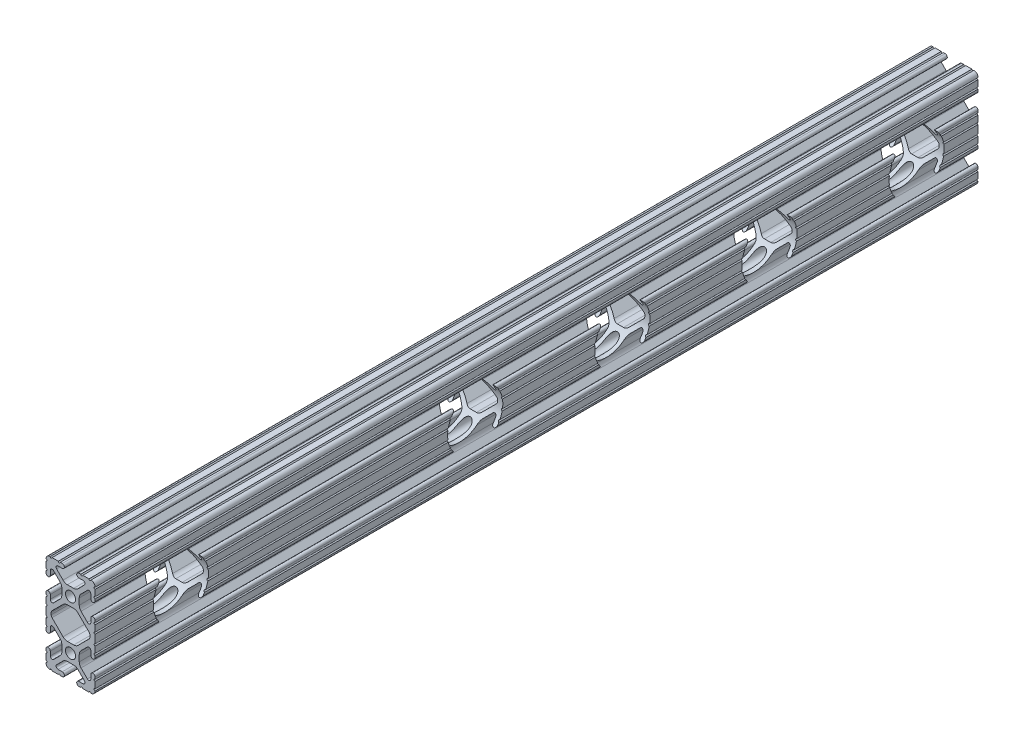
from build123d import *

# Parameters (mm, degrees)
SKETCH1_R               = 2.6035
BOSS_EXTRUDE1_DEPTH     = 457.2
CUT_EXTRUDE1_DEPTH      = 891.178507316
CUT_EXTRUDE1_DEPTH_BACK = 891.178507316
SKETCH2_R               = 14.2875


with BuildPart() as part:
    # Sketch1 → Boss-Extrude1 (new body)
    with BuildSketch(Plane(origin=(0, 0, -889), x_dir=(-1, 0, 0), z_dir=(0, 0, -1))):
        with BuildLine():
            Line((9.5504, 38.1), (6.3246, 38.1))
            ThreePointArc((6.3246, 38.1), (5.8166, 37.592), (5.3086, 38.1))
            Line((5.3086, 38.1), (4.302307889, 38.1))
            ThreePointArc((4.302307889, 38.1), (3.197407889, 36.9951), (4.302307889, 35.8902))
            Line((4.302307889, 35.8902), (6.474794456, 35.8902))
            ThreePointArc((6.474794456, 35.8902), (7.413456061, 35.263006367), (7.193214945, 34.15577951))
            Line((7.193214945, 34.15577951), (3.875871405, 30.83843597))
            ThreePointArc((3.875871405, 30.83843597), (2.845827272, 30.150182484), (1.630807374, 29.9085))
            Line((1.630807374, 29.9085), (-1.630807374, 29.9085))
            ThreePointArc((-1.630807374, 29.9085), (-2.845827272, 30.150182484), (-3.875871405, 30.83843597))
            Line((-3.875871405, 30.83843597), (-7.193214945, 34.15577951))
            ThreePointArc((-7.193214945, 34.15577951), (-7.413456061, 35.263006367), (-6.474794456, 35.8902))
            Line((-6.474794456, 35.8902), (-4.302307889, 35.8902))
            ThreePointArc((-4.302307889, 35.8902), (-3.197407889, 36.9951), (-4.302307889, 38.1))
            Line((-4.302307889, 38.1), (-5.3086, 38.1))
            ThreePointArc((-5.3086, 38.1), (-5.8166, 37.592), (-6.3246, 38.1))
            Line((-6.3246, 38.1), (-9.5504, 38.1))
            ThreePointArc((-9.5504, 38.1), (-10.06475, 37.591960804), (-10.5791, 38.1))
            ThreePointArc((-10.5791, 38.1), (-12.082561002, 37.482561002), (-12.7, 35.9791))
            ThreePointArc((-12.7, 35.9791), (-12.191960804, 35.46475), (-12.7, 34.9504))
            Line((-12.7, 34.9504), (-12.7, 31.7246))
            ThreePointArc((-12.7, 31.7246), (-12.192, 31.2166), (-12.7, 30.7086))
            Line((-12.7, 30.7086), (-12.7, 29.702307889))
            ThreePointArc((-12.7, 29.702307889), (-11.5951, 28.597407889), (-10.4902, 29.702307889))
            Line((-10.4902, 29.702307889), (-10.4902, 31.874794456))
            ThreePointArc((-10.4902, 31.874794456), (-9.863006367, 32.813456061), (-8.75577951, 32.593214945))
            Line((-8.75577951, 32.593214945), (-5.43843597, 29.275871405))
            ThreePointArc((-5.43843597, 29.275871405), (-4.750182484, 28.245827272), (-4.5085, 27.030807374))
            Line((-4.5085, 27.030807374), (-4.5085, 23.769192626))
            ThreePointArc((-4.5085, 23.769192626), (-4.750182484, 22.554172728), (-5.43843597, 21.524128595))
            Line((-5.43843597, 21.524128595), (-8.75577951, 18.206785055))
            ThreePointArc((-8.75577951, 18.206785055), (-9.863006367, 17.986543939), (-10.4902, 18.925205544))
            Line((-10.4902, 18.925205544), (-10.4902, 21.097692082))
            ThreePointArc((-10.4902, 21.097692082), (-11.5951, 22.202592082), (-12.7, 21.097692082))
            Line((-12.7, 21.097692082), (-12.7, 20.0914))
            ThreePointArc((-12.7, 20.0914), (-12.192, 19.5834), (-12.7, 19.0754))
            Line((-12.7, 19.0754), (-12.7, 15.8496))
            ThreePointArc((-12.7, 15.8496), (-12.192, 15.3416), (-12.7, 14.8336))
            Line((-12.7, 14.8336), (-12.7, 10.5664))
            ThreePointArc((-12.7, 10.5664), (-12.192, 10.0584), (-12.7, 9.5504))
            Line((-12.7, 9.5504), (-12.7, 6.3246))
            ThreePointArc((-12.7, 6.3246), (-12.192, 5.8166), (-12.7, 5.3086))
            Line((-12.7, 5.3086), (-12.7, 4.302307889))
            ThreePointArc((-12.7, 4.302307889), (-11.5951, 3.197407889), (-10.4902, 4.302307889))
            Line((-10.4902, 4.302307889), (-10.4902, 6.474794456))
            ThreePointArc((-10.4902, 6.474794456), (-9.863006367, 7.413456061), (-8.75577951, 7.193214945))
            Line((-8.75577951, 7.193214945), (-5.43843597, 3.875871405))
            ThreePointArc((-5.43843597, 3.875871405), (-4.750182484, 2.845827272), (-4.5085, 1.630807374))
            Line((-4.5085, 1.630807374), (-4.5085, -1.630807374))
            ThreePointArc((-4.5085, -1.630807374), (-4.750182484, -2.845827272), (-5.43843597, -3.875871405))
            Line((-5.43843597, -3.875871405), (-8.75577951, -7.193214945))
            ThreePointArc((-8.75577951, -7.193214945), (-9.863006367, -7.413456061), (-10.4902, -6.474794456))
            Line((-10.4902, -6.474794456), (-10.4902, -4.302307889))
            ThreePointArc((-10.4902, -4.302307889), (-11.5951, -3.197407889), (-12.7, -4.302307889))
            Line((-12.7, -4.302307889), (-12.7, -5.3086))
            ThreePointArc((-12.7, -5.3086), (-12.192, -5.8166), (-12.7, -6.3246))
            Line((-12.7, -6.3246), (-12.7, -9.5504))
            ThreePointArc((-12.7, -9.5504), (-12.191960804, -10.06475), (-12.7, -10.5791))
            ThreePointArc((-12.7, -10.5791), (-12.082561002, -12.082561002), (-10.5791, -12.7))
            ThreePointArc((-10.5791, -12.7), (-10.06475, -12.191960804), (-9.5504, -12.7))
            Line((-9.5504, -12.7), (-6.3246, -12.7))
            ThreePointArc((-6.3246, -12.7), (-5.8166, -12.192), (-5.3086, -12.7))
            Line((-5.3086, -12.7), (-4.302307889, -12.7))
            ThreePointArc((-4.302307889, -12.7), (-3.197407889, -11.5951), (-4.302307889, -10.4902))
            Line((-4.302307889, -10.4902), (-6.474794456, -10.4902))
            ThreePointArc((-6.474794456, -10.4902), (-7.413456061, -9.863006367), (-7.193214945, -8.75577951))
            Line((-7.193214945, -8.75577951), (-3.875871405, -5.43843597))
            ThreePointArc((-3.875871405, -5.43843597), (-2.845827272, -4.750182484), (-1.630807374, -4.5085))
            Line((-1.630807374, -4.5085), (1.630807374, -4.5085))
            ThreePointArc((1.630807374, -4.5085), (2.845827272, -4.750182484), (3.875871405, -5.43843597))
            Line((3.875871405, -5.43843597), (7.193214945, -8.75577951))
            ThreePointArc((7.193214945, -8.75577951), (7.413456061, -9.863006367), (6.474794456, -10.4902))
            Line((6.474794456, -10.4902), (4.302307889, -10.4902))
            ThreePointArc((4.302307889, -10.4902), (3.197407889, -11.5951), (4.302307889, -12.7))
            Line((4.302307889, -12.7), (5.3086, -12.7))
            ThreePointArc((5.3086, -12.7), (5.8166, -12.192), (6.3246, -12.7))
            Line((6.3246, -12.7), (9.5504, -12.7))
            ThreePointArc((9.5504, -12.7), (10.06475, -12.191960804), (10.5791, -12.7))
            ThreePointArc((10.5791, -12.7), (12.082561002, -12.082561002), (12.7, -10.5791))
            ThreePointArc((12.7, -10.5791), (12.191960804, -10.06475), (12.7, -9.5504))
            Line((12.7, -9.5504), (12.7, -6.3246))
            ThreePointArc((12.7, -6.3246), (12.192, -5.8166), (12.7, -5.3086))
            Line((12.7, -5.3086), (12.7, -4.302307889))
            ThreePointArc((12.7, -4.302307889), (11.5951, -3.197407889), (10.4902, -4.302307889))
            Line((10.4902, -4.302307889), (10.4902, -6.474794456))
            ThreePointArc((10.4902, -6.474794456), (9.863006367, -7.413456061), (8.75577951, -7.193214945))
            Line((8.75577951, -7.193214945), (5.43843597, -3.875871405))
            ThreePointArc((5.43843597, -3.875871405), (4.750182484, -2.845827272), (4.5085, -1.630807374))
            Line((4.5085, -1.630807374), (4.5085, 1.630807374))
            ThreePointArc((4.5085, 1.630807374), (4.750182484, 2.845827272), (5.43843597, 3.875871405))
            Line((5.43843597, 3.875871405), (8.75577951, 7.193214945))
            ThreePointArc((8.75577951, 7.193214945), (9.863006367, 7.413456061), (10.4902, 6.474794456))
            Line((10.4902, 6.474794456), (10.4902, 4.302307889))
            ThreePointArc((10.4902, 4.302307889), (11.5951, 3.197407889), (12.7, 4.302307889))
            Line((12.7, 4.302307889), (12.7, 5.3086))
            ThreePointArc((12.7, 5.3086), (12.192, 5.8166), (12.7, 6.3246))
            Line((12.7, 6.3246), (12.7, 9.5504))
            ThreePointArc((12.7, 9.5504), (12.192, 10.0584), (12.7, 10.5664))
            Line((12.7, 10.5664), (12.7, 14.8336))
            ThreePointArc((12.7, 14.8336), (12.192, 15.3416), (12.7, 15.8496))
            Line((12.7, 15.8496), (12.7, 19.0754))
            ThreePointArc((12.7, 19.0754), (12.192, 19.5834), (12.7, 20.0914))
            Line((12.7, 20.0914), (12.7, 21.097692111))
            ThreePointArc((12.7, 21.097692111), (11.5951, 22.202592111), (10.4902, 21.097692111))
            Line((10.4902, 21.097692111), (10.4902, 18.925205544))
            ThreePointArc((10.4902, 18.925205544), (9.863006367, 17.986543939), (8.75577951, 18.206785055))
            Line((8.75577951, 18.206785055), (5.43843597, 21.524128595))
            ThreePointArc((5.43843597, 21.524128595), (4.750182484, 22.554172728), (4.5085, 23.769192626))
            Line((4.5085, 23.769192626), (4.5085, 27.030807374))
            ThreePointArc((4.5085, 27.030807374), (4.750182484, 28.245827272), (5.43843597, 29.275871405))
            Line((5.43843597, 29.275871405), (8.75577951, 32.593214945))
            ThreePointArc((8.75577951, 32.593214945), (9.863006367, 32.813456061), (10.4902, 31.874794456))
            Line((10.4902, 31.874794456), (10.4902, 29.702307889))
            ThreePointArc((10.4902, 29.702307889), (11.5951, 28.597407889), (12.7, 29.702307889))
            Line((12.7, 29.702307889), (12.7, 30.7086))
            ThreePointArc((12.7, 30.7086), (12.192, 31.2166), (12.7, 31.7246))
            Line((12.7, 31.7246), (12.7, 34.9504))
            ThreePointArc((12.7, 34.9504), (12.191960804, 35.46475), (12.7, 35.9791))
            ThreePointArc((12.7, 35.9791), (12.082561002, 37.482561002), (10.5791, 38.1))
            ThreePointArc((10.5791, 38.1), (10.06475, 37.591960804), (9.5504, 38.1))
        make_face()
        with Locations(Location((0, 25.4, 0), (0, 0, 180))):
            Circle(SKETCH1_R, mode=Mode.SUBTRACT)
        with Locations(Location((0, 0, 0), (0, 0, 180))):
            Circle(SKETCH1_R, mode=Mode.SUBTRACT)
        with BuildLine():
            Line((10.033, 13.152131917), (10.033, 12.247868083))
            ThreePointArc((10.033, 12.247868083), (9.913125488, 11.645218214), (9.571751759, 11.134316324))
            Line((9.571751759, 11.134316324), (3.875871405, 5.43843597))
            ThreePointArc((3.875871405, 5.43843597), (2.845827272, 4.750182484), (1.630807374, 4.5085))
            Line((1.630807374, 4.5085), (-1.630807374, 4.5085))
            ThreePointArc((-1.630807374, 4.5085), (-2.845827272, 4.750182484), (-3.875871405, 5.43843597))
            Line((-3.875871405, 5.43843597), (-9.571751759, 11.134316324))
            ThreePointArc((-9.571751759, 11.134316324), (-9.913125488, 11.645218214), (-10.033, 12.247868083))
            Line((-10.033, 12.247868083), (-10.033, 13.152131917))
            ThreePointArc((-10.033, 13.152131917), (-9.913125488, 13.754781786), (-9.571751759, 14.265683676))
            Line((-9.571751759, 14.265683676), (-3.875871405, 19.96156403))
            ThreePointArc((-3.875871405, 19.96156403), (-2.845827272, 20.649817516), (-1.630807374, 20.8915))
            Line((-1.630807374, 20.8915), (1.630807374, 20.8915))
            ThreePointArc((1.630807374, 20.8915), (2.845827272, 20.649817516), (3.875871405, 19.96156403))
            Line((3.875871405, 19.96156403), (9.571751759, 14.265683676))
            ThreePointArc((9.571751759, 14.265683676), (9.913125488, 13.754781786), (10.033, 13.152131917))
        make_face(mode=Mode.SUBTRACT)
    extrude(amount=-BOSS_EXTRUDE1_DEPTH)

    # Sketch2 → Cut-Extrude1 (cut, two sides: drawn at the far end of the back side and taken through both)
    with BuildSketch(Plane(origin=(12.7, 0, 0), x_dir=(0, 0, -1), z_dir=(1, 0, 0)).offset(-CUT_EXTRUDE1_DEPTH_BACK)):
        with Locations(Location((857.25, 12.7, 0), (0, 0, 50.78206777))):
            Circle(SKETCH2_R)
        with Locations(Location((781.05, 12.7, 0), (0, 0, 50.78206777))):
            Circle(SKETCH2_R)
        with Locations(Location((704.85, 12.7, 0), (0, 0, 50.78206777))):
            Circle(SKETCH2_R)
        with Locations(Location((628.65, 12.7, 0), (0, 0, 50.78206777))):
            Circle(SKETCH2_R)
        with Locations(Location((476.25, 12.7, 0), (0, 0, 50.78206777))):
            Circle(SKETCH2_R)
    extrude(amount=CUT_EXTRUDE1_DEPTH + CUT_EXTRUDE1_DEPTH_BACK, mode=Mode.SUBTRACT)


solid = part.part
